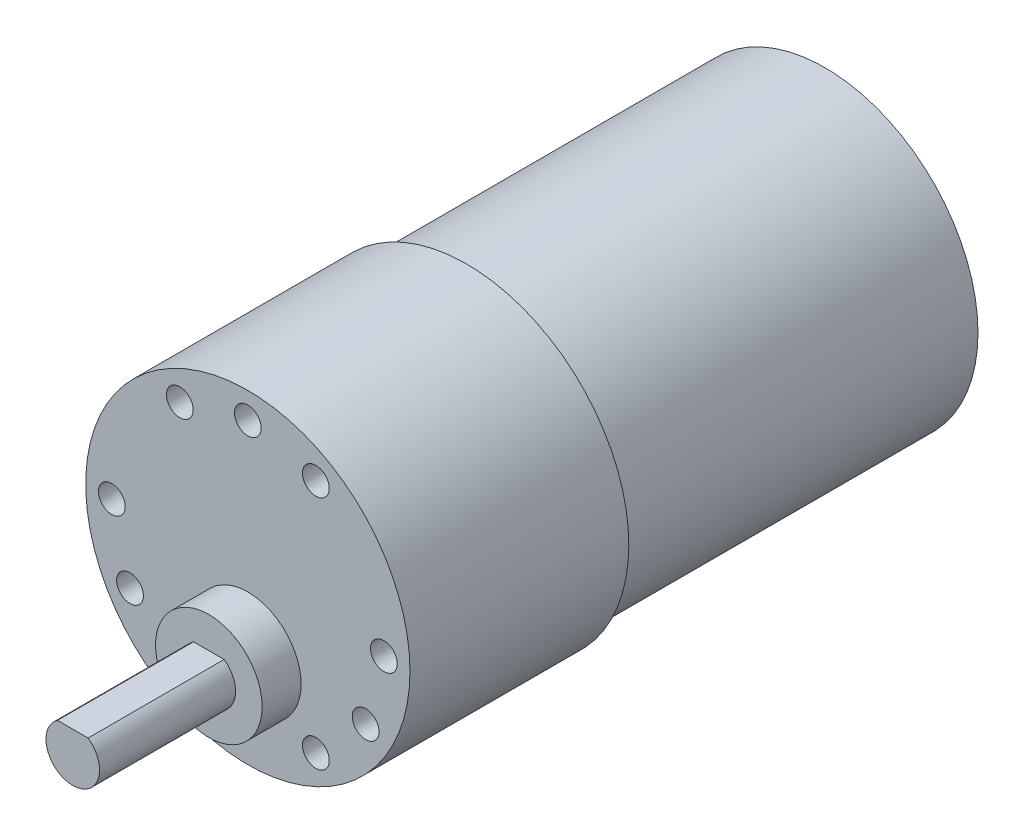
from build123d import *

# Parameters (mm, degrees)
SKETCH1_R           = 18.161
BOSS_EXTRUDE1_DEPTH = 24.511
SKETCH5_R           = 5.969
BOSS_EXTRUDE5_DEPTH = 4.3688
BOSS_EXTRUDE6_DEPTH = 15.24
CIRPATTERN2_COUNT   = 12
SKETCH2_R           = 17.145
BOSS_EXTRUDE2_DEPTH = 40.132
SKETCH3_R           = 3.048
BOSS_EXTRUDE3_DEPTH = 3.81
SKETCH13_R          = 16.637
CUT_EXTRUDE1_DEPTH  = 1.016
SKETCH15_W          = 2.54
SKETCH15_H          = 5.08
SKETCH15_R          = 0.4445
BOSS_EXTRUDE7_DEPTH = 0.254
SKETCH16_W          = 2.54
SKETCH16_H          = 5.08
SKETCH16_R          = 0.678606607
BOSS_EXTRUDE8_DEPTH = 0.254


with BuildPart() as part:
    # Sketch1 → Boss-Extrude1 (new body)
    with BuildSketch(Plane.XY):
        Circle(SKETCH1_R)
    extrude(amount=BOSS_EXTRUDE1_DEPTH)

    # Sketch5 → Boss-Extrude5 (add)
    with BuildSketch(Plane.XY.offset(24.511)):
        with Locations((0, -7.366)):
            Circle(SKETCH5_R)
    extrude(amount=BOSS_EXTRUDE5_DEPTH)

    # Sketch6 → Boss-Extrude6 (add)
    with BuildSketch(Plane.XY.offset(28.8798)):
        with BuildLine():
            Line((-1.715657017, -4.905), (1.715657017, -4.905))
            ThreePointArc((1.715657017, -4.905), (0, -10.366), (-1.715657017, -4.905))
        make_face()
    extrude(amount=BOSS_EXTRUDE6_DEPTH)

    # Sketch12 → Ø3.0mm Dowel Hole1 (revolve, cut)
    with BuildSketch(Plane(origin=(0, 15.24, 24.511), x_dir=(0, -1, 0), z_dir=(1, 0, 0))):
        Polygon((0, 0), (0, 11.061290929), (1.5, 10.16), (1.5, 0), align=None)
    f_3_0mm_dowel_hole1 = revolve(axis=Axis((0, 15.24, 30.861), (0, 0, -1)), mode=Mode.SUBTRACT)

    # CirPattern2: Ø3.0mm Dowel Hole1 ×12 about axis, 3 skipped
    cirpattern2_axis = Axis((0, 0, 0), (0, 0, -1))
    add([f_3_0mm_dowel_hole1.rotate(cirpattern2_axis, i * 360 / CIRPATTERN2_COUNT) for i in range(1, CIRPATTERN2_COUNT) if i not in (2, 6, 10)], mode=Mode.SUBTRACT)

    # Sketch2 → Boss-Extrude2 (add)
    with BuildSketch(Plane(origin=(0, 0, 0), x_dir=(-1, 0, 0), z_dir=(0, 0, -1))):
        Circle(SKETCH2_R)
    extrude(amount=BOSS_EXTRUDE2_DEPTH)

    # Sketch3 → Boss-Extrude3 (add)
    with BuildSketch(Plane(origin=(0, 0, -40.132), x_dir=(-1, 0, 0), z_dir=(0, 0, -1))):
        Circle(SKETCH3_R)
    extrude(amount=BOSS_EXTRUDE3_DEPTH)

    # Sketch13 → Cut-Extrude1 (cut)
    with BuildSketch(Plane(origin=(0, 0, -40.132), x_dir=(-1, 0, 0), z_dir=(0, 0, -1))):
        Circle(SKETCH13_R)
    extrude(amount=-CUT_EXTRUDE1_DEPTH, mode=Mode.SUBTRACT)

    # Sketch15 → Boss-Extrude7 (add, symmetric)
    with BuildSketch(Plane(origin=(0, 0, 0), x_dir=(0.64278761, -0.766044443, 0), z_dir=(0.766044443, 0.64278761, 0))):
        with Locations((10.16, 41.656)):
            Rectangle(SKETCH15_W, SKETCH15_H)
        with Locations((10.16, 42.926)):
            Circle(SKETCH15_R, mode=Mode.SUBTRACT)
    extrude(amount=BOSS_EXTRUDE7_DEPTH, both=True)

    # Sketch16 → Boss-Extrude8 (add, symmetric)
    with BuildSketch(Plane(origin=(0, 0, 0), x_dir=(-0.258819045, -0.965925826, 0), z_dir=(0.965925826, -0.258819045, 0))):
        with Locations((11.43, 41.656)):
            Rectangle(SKETCH16_W, SKETCH16_H)
        with Locations((11.43, 42.926)):
            Circle(SKETCH16_R, mode=Mode.SUBTRACT)
    extrude(amount=BOSS_EXTRUDE8_DEPTH, both=True)


solid = part.part
